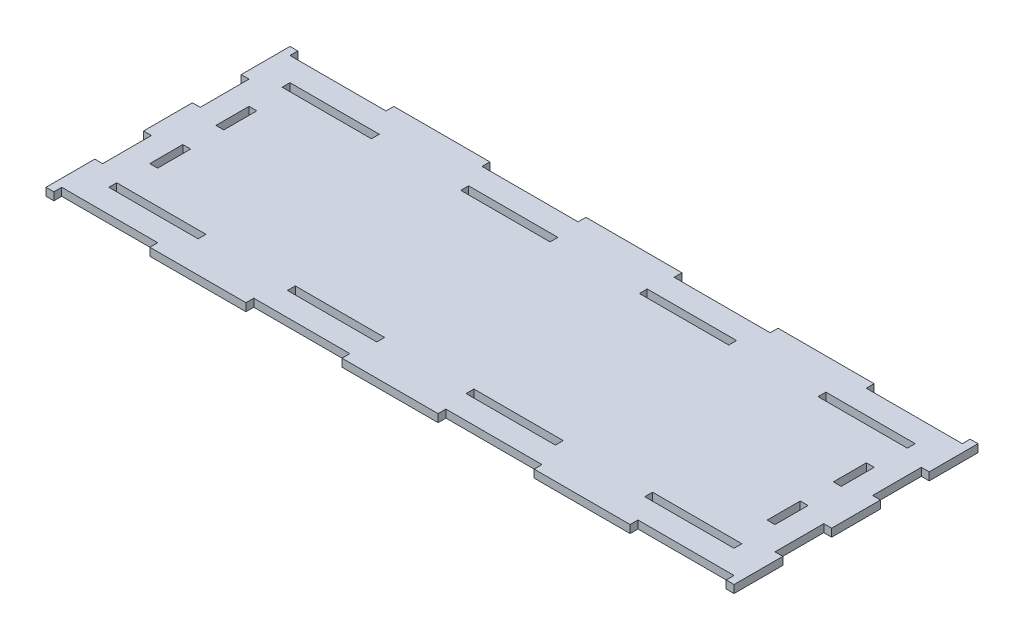
from build123d import *

# Parameters (mm, degrees)
SKETCH1_W           = 466
SKETCH1_H           = 126.5
BOSS_EXTRUDE1_DEPTH = 6
SKETCH2_W           = 514
SKETCH2_H           = 174.5
SKETCH2_W_2         = 68.285714286
SKETCH2_H_2         = 6
SKETCH2_W_3         = 68.285714285
SKETCH2_W_4         = 73.428571428
SKETCH2_W_5         = 6
SKETCH2_H_3         = 25.3
SKETCH2_H_4         = 37.3
BOSS_EXTRUDE2_DEPTH = 6


with BuildPart() as part:
    # Sketch1 → Boss-Extrude1 (new body)
    with BuildSketch(Plane(origin=(0, 0, 0), x_dir=(1, 0, 0), z_dir=(0, 1, 0))):
        Rectangle(SKETCH1_W, SKETCH1_H)
    extrude(amount=BOSS_EXTRUDE1_DEPTH)

    # Sketch2 → Boss-Extrude2 (add)
    with BuildSketch(Plane(origin=(0, 6, 0), x_dir=(1, 0, 0), z_dir=(0, 1, 0))):
        Rectangle(SKETCH2_W, SKETCH2_H)
        Polygon((170.714285714, 69.25), (102.428571429, 69.25), (34.142857143, 69.25), (-34.142857143, 69.25), (-102.428571429, 69.25), (-170.714285714, 69.25), (-239, 69.25), (-239, 63.25), (-239, 37.95), (-239, 12.65), (-239, -12.65), (-239, -37.95), (-239, -63.25), (-239, -69.25), (239, -69.25), (239, 69.25), align=None, mode=Mode.SUBTRACT)
        with Locations((0, 66.25)):
            Rectangle(SKETCH2_W_2, SKETCH2_H_2)
        with Locations((-136.571428572, 66.25)):
            Rectangle(SKETCH2_W_3, SKETCH2_H_2)
        with Locations((136.571428572, 66.25)):
            Rectangle(SKETCH2_W_3, SKETCH2_H_2)
        with Locations((-146.857142857, 90.25)):
            Rectangle(SKETCH2_W_4, SKETCH2_H_2)
        with Locations((0, 90.25)):
            Rectangle(SKETCH2_W_4, SKETCH2_H_2)
        with Locations((146.857142857, 90.25)):
            Rectangle(SKETCH2_W_4, SKETCH2_H_2)
        with Locations((-236, 50.6)):
            Rectangle(SKETCH2_W_5, SKETCH2_H_3)
        Polygon((-263, 55.95), (-257, 55.95), (-257, 87.25), (-257, 93.25), (-263, 93.25), align=None)
        with Locations((-236, 0)):
            Rectangle(SKETCH2_W_5, SKETCH2_H_3)
        with Locations((-260, 0)):
            Rectangle(SKETCH2_W_5, SKETCH2_H_4)
        with Locations((-236, -50.6)):
            Rectangle(SKETCH2_W_5, SKETCH2_H_3)
        Polygon((-257, -93.25), (-257, -87.25), (-257, -55.95), (-263, -55.95), (-263, -93.25), align=None)
    boss_extrude2 = extrude(amount=-BOSS_EXTRUDE2_DEPTH)

    # Mirror2: Boss-Extrude2 across plane
    add(boss_extrude2.mirror(Plane.XY))

    # Mirror3: Boss-Extrude2 across plane
    add(boss_extrude2.mirror(Plane(origin=(0, 0, 0), x_dir=(0, 0, 1), z_dir=(1, 0, 0))))


solid = part.part
